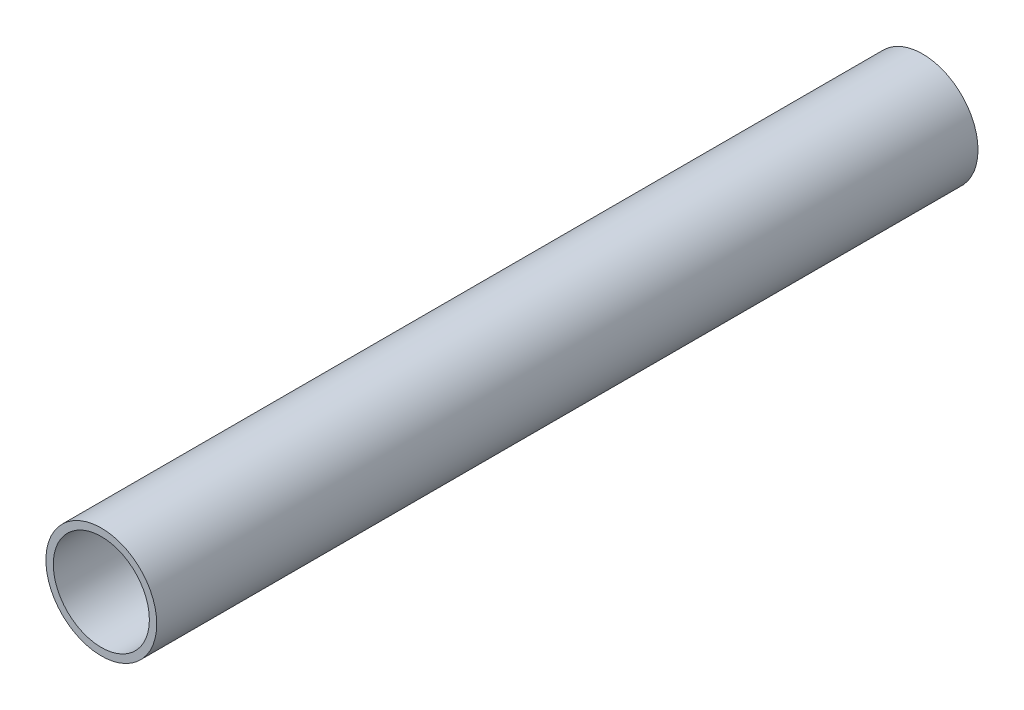
from build123d import *

# Parameters (mm, degrees)
SKETCH1_R           = 13.5
SKETCH1_R_2         = 11.7
BOSS_EXTRUDE1_DEPTH = 200


with BuildPart() as part:
    # Sketch1 → Boss-Extrude1 (new body)
    with BuildSketch(Plane.XY):
        Circle(SKETCH1_R)
        Circle(SKETCH1_R_2, mode=Mode.SUBTRACT)
    extrude(amount=BOSS_EXTRUDE1_DEPTH)


solid = part.part
